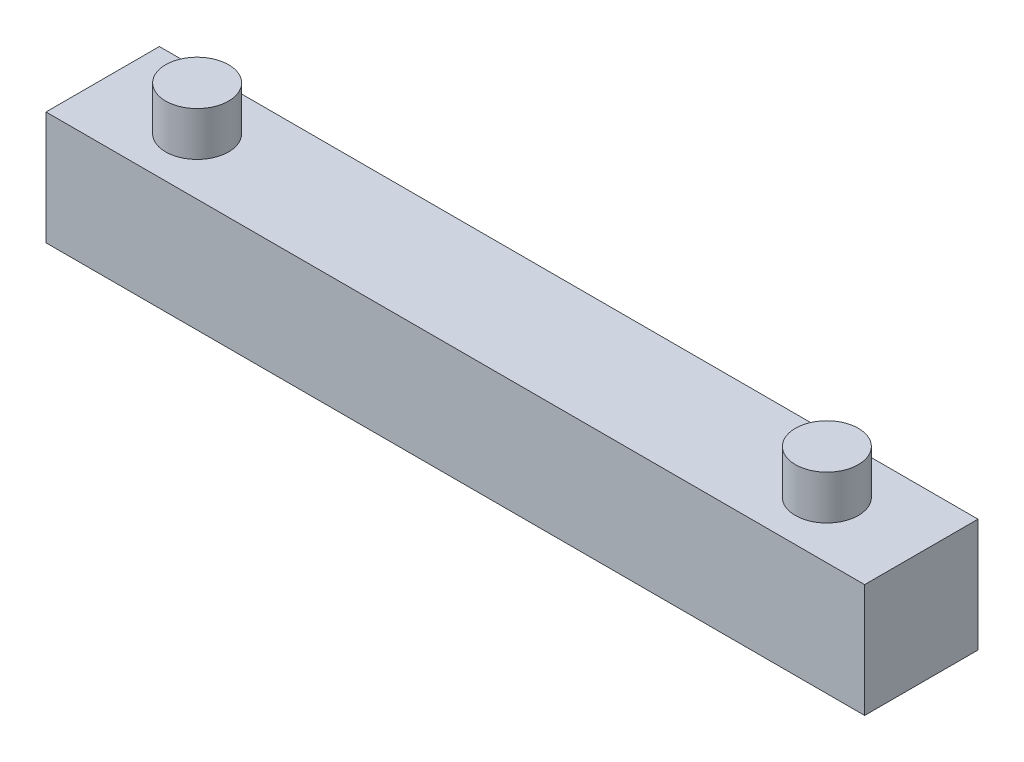
from build123d import *

# Parameters (mm, degrees)
SKETCH1_W           = 65
SKETCH1_H           = 9
BOSS_EXTRUDE1_DEPTH = 9
SKETCH2_R           = 2.5
BOSS_EXTRUDE2_DEPTH = 3.5


with BuildPart() as part:
    # Sketch1 → Boss-Extrude1 (new body)
    with BuildSketch(Plane(origin=(0, 0, 0), x_dir=(1, 0, 0), z_dir=(0, 1, 0))):
        with Locations((32.5, -4.5)):
            Rectangle(SKETCH1_W, SKETCH1_H)
    extrude(amount=BOSS_EXTRUDE1_DEPTH)

    # Sketch2 → Boss-Extrude2 (add)
    with BuildSketch(Plane(origin=(0, 9, 0), x_dir=(1, 0, 0), z_dir=(0, 1, 0))):
        with Locations(Location((7.5, -4.5, 0), (0, 0, 270))):  # turned: the seam where the file's is
            Circle(SKETCH2_R)
        with Locations(Location((57.5, -4.5, 0), (0, 0, 270))):  # turned: the seam where the file's is
            Circle(SKETCH2_R)
    extrude(amount=BOSS_EXTRUDE2_DEPTH)


solid = part.part
